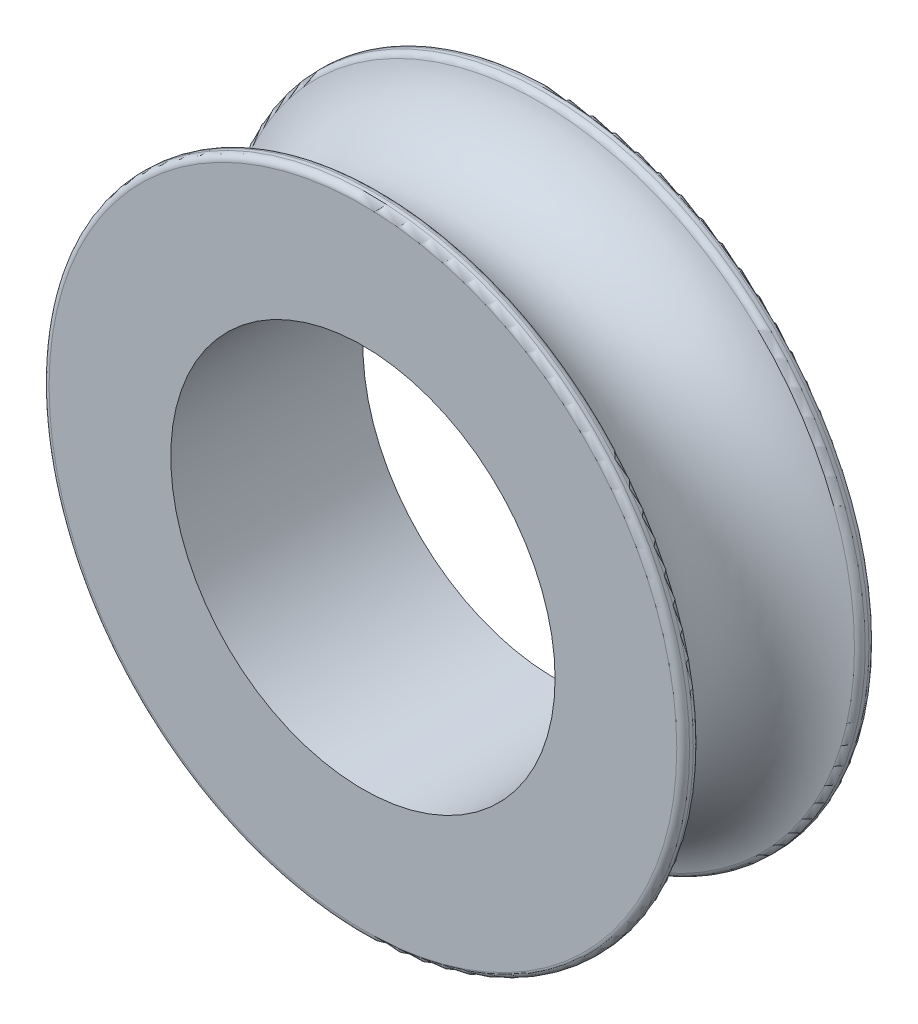
from build123d import *

# Parameters (mm, degrees)
CONG_2_R = 0.1


with BuildPart() as part:
    # Esquisse1 → Révolution1 (revolve)
    with BuildSketch(Plane(origin=(0, 0, 0), x_dir=(0, 0, -1), z_dir=(1, 0, 0))):
        with BuildLine():
            Line((-1.5, 3), (-1.5, 5))
            Line((-1.5, 5), (-1.264911064, 5))
            ThreePointArc((-1.264911064, 5), (0, 4), (1.264911064, 5))
            Line((1.264911064, 5), (1.5, 5))
            Line((1.5, 5), (1.5, 3))
            Line((1.5, 3), (-1.5, 3))
        make_face()
    revolve(axis=Axis((0, 0, 0), (0, 0, -1)))

    # Congé2
    cong_2_edges = [part.edges().sort_by_distance(p)[0] for p in [
        (0, -5, -1.5),
        (0, -5, -1.264911064),
        (0, -5, 1.264911064),
        (0, -5, 1.5),
    ]]
    fillet(cong_2_edges, radius=CONG_2_R)


solid = part.part
